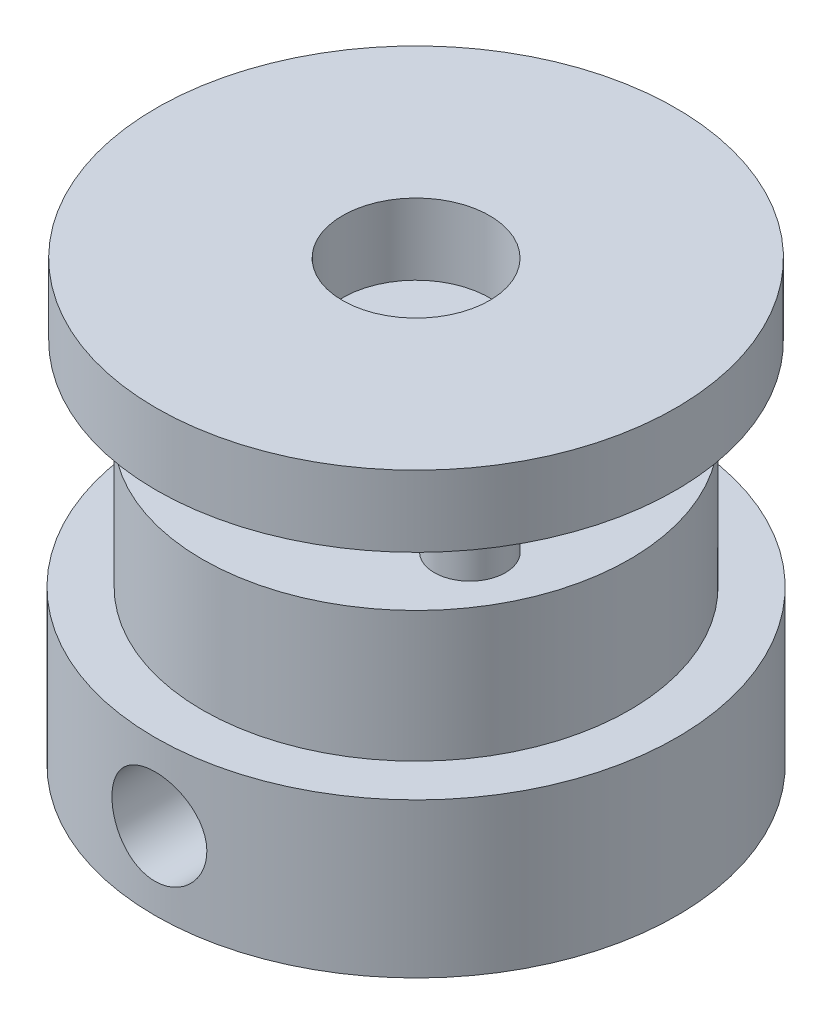
from build123d import *

# Parameters (mm, degrees)
SKETCH1_R           = 11
BOSS_EXTRUDE1_DEPTH = 6.5
SKETCH2_R           = 9
BOSS_EXTRUDE2_DEPTH = 5.5
SKETCH3_R           = 3
CUT_EXTRUDE1_DEPTH  = 13
SKETCH4_R           = 1.5
BOSS_EXTRUDE3_DEPTH = 3.5
CIRPATTERN1_COUNT   = 3
SKETCH5_R           = 10.95
SKETCH5_R_2         = 3.1
BOSS_EXTRUDE4_DEPTH = 3
SKETCH7_R           = 2
CUT_EXTRUDE2_DEPTH  = 12


with BuildPart() as part:
    # Sketch1 → Boss-Extrude1 (new body)
    with BuildSketch(Plane(origin=(0, 0, 0), x_dir=(1, 0, 0), z_dir=(0, 1, 0))):
        Circle(SKETCH1_R)
    extrude(amount=BOSS_EXTRUDE1_DEPTH)

    # Sketch2 → Boss-Extrude2 (add)
    with BuildSketch(Plane(origin=(0, 6.5, 0), x_dir=(1, 0, 0), z_dir=(0, 1, 0))):
        Circle(SKETCH2_R)
    extrude(amount=BOSS_EXTRUDE2_DEPTH)

    # Sketch3 → Cut-Extrude1 (cut, through all)
    with BuildSketch(Plane(origin=(0, 12, 0), x_dir=(1, 0, 0), z_dir=(0, 1, 0))):
        Circle(SKETCH3_R)
    extrude(amount=-CUT_EXTRUDE1_DEPTH, mode=Mode.SUBTRACT)

    # Sketch4 → Boss-Extrude3 (add)
    with BuildSketch(Plane(origin=(0, 12, 0), x_dir=(1, 0, 0), z_dir=(0, 1, 0))):
        with Locations((0, 6.2)):
            Circle(SKETCH4_R)
    boss_extrude3 = extrude(amount=BOSS_EXTRUDE3_DEPTH)

    # CirPattern1: Boss-Extrude3 ×3 about axis
    cirpattern1_axis = Axis((0, 0, 0), (0, 1, 0))
    for i in range(1, CIRPATTERN1_COUNT):
        add(boss_extrude3.rotate(cirpattern1_axis, i * 360 / CIRPATTERN1_COUNT))

    # Sketch5 → Boss-Extrude4 (add)
    with BuildSketch(Plane(origin=(0, 15.5, 0), x_dir=(1, 0, 0), z_dir=(0, 1, 0))):
        Circle(SKETCH5_R)
        Circle(SKETCH5_R_2, mode=Mode.SUBTRACT)
    extrude(amount=BOSS_EXTRUDE4_DEPTH)

    # Sketch7 → Cut-Extrude2 (cut, through all)
    with BuildSketch(Plane.XY):
        with Locations((0, 3.25)):
            Circle(SKETCH7_R)
    extrude(amount=CUT_EXTRUDE2_DEPTH, mode=Mode.SUBTRACT)


solid = part.part
